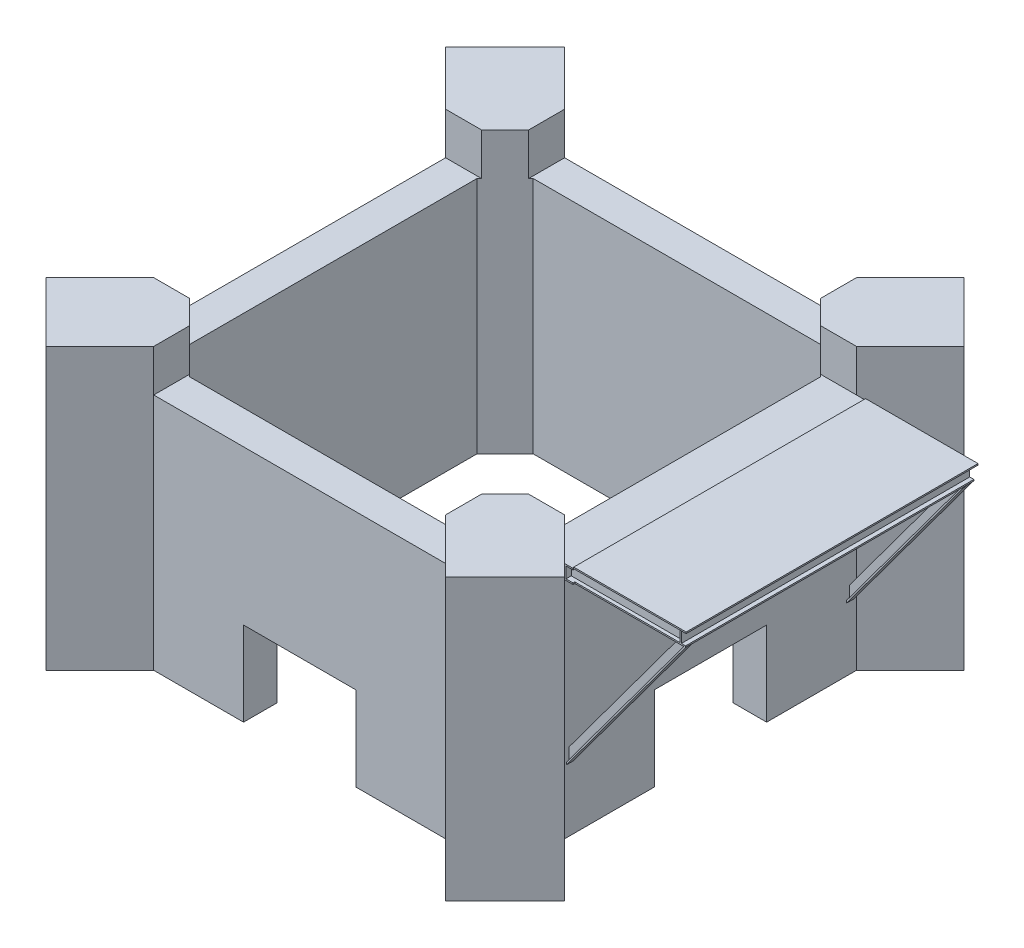
from build123d import *

# Parameters (mm, degrees)
BOSS_EXTRUDE1_DEPTH  = 10000
CUT_EXTRUDE3_DEPTH   = 1500
SKETCH5_W            = 4000
SKETCH5_H            = 3000
CUT_EXTRUDE4_DEPTH   = 1353
SKETCH6_W            = 4000
SKETCH6_H            = 3000
CUT_EXTRUDE5_DEPTH   = 1353
SKETCH7_W            = 10402.254821559
SKETCH7_H            = 500
BOSS_EXTRUDE2_DEPTH  = 50
SKETCH8_W            = 10402.254821559
SKETCH8_H            = 50
BOSS_EXTRUDE3_DEPTH  = 250
SKETCH9_W            = 50
SKETCH9_H            = 400
BOSS_EXTRUDE4_DEPTH  = 4000
SKETCH10_W           = 3600
SKETCH10_H           = 300
BOSS_EXTRUDE5_DEPTH  = 50
SKETCH11_W           = 3600
SKETCH11_H           = 300
BOSS_EXTRUDE6_DEPTH  = 50
SKETCH12_W           = 10277.25482156
SKETCH12_H           = 400
BOSS_EXTRUDE7_DEPTH  = 50
SKETCH13_W           = 350
SKETCH13_H           = 10277.254821559
BOSS_EXTRUDE8_DEPTH  = 50
SKETCH15_W           = 4008.15465075
SKETCH15_H           = 10402.254821559
BOSS_EXTRUDE11_DEPTH = 50
SKETCH14_W           = 350
SKETCH14_H           = 10277.25482156
BOSS_EXTRUDE9_DEPTH  = 50
BOSS_EXTRUDE12_DEPTH = 50
SKETCH17_W           = 238.62741078
SKETCH17_H           = 7184.490164885
BOSS_EXTRUDE17_DEPTH = 50
BOSS_EXTRUDE18_DEPTH = 50
SKETCH19_W           = 250
SKETCH19_H           = 7222.055032397
BOSS_EXTRUDE20_DEPTH = 50


with BuildPart() as part:
    # Sketch1 → Boss-Extrude1 (new body)
    with BuildSketch(Plane(origin=(0, 0, 0), x_dir=(1, 0, 0), z_dir=(0, 1, 0))):
        Polygon((-5000, 7121.320343559), (-7121.32034356, 5000), (-7322.447754339, 5201.127410779), (-7322.447754339, -5201.127410779), (-7121.32034356, -5000), (-5000, -7121.320343559), (-5201.12741078, -7322.447754339), (5201.12741078, -7322.447754339), (5000, -7121.320343559), (7121.320343559, -5000), (7322.447754339, -5201.12741078), (7322.447754339, 5201.12741078), (7121.320343559, 5000), (5000, 7121.320343559), (5201.12741078, 7322.447754339), (-5201.12741078, 7322.447754339), align=None)
        Polygon((-5122.447754339, 6122.447754339), (5122.447754339, 6122.447754339), (6122.447754339, 5122.447754339), (6122.447754339, -5122.447754339), (5122.447754339, -6122.447754339), (-5122.447754339, -6122.447754339), (-6122.447754339, -5122.447754339), (-6122.447754339, 5122.447754339), align=None, mode=Mode.SUBTRACT)
        Polygon((7322.447754339, 7322.447754339), (5201.12741078, 7322.447754339), (5000, 7121.320343559), (7121.320343559, 5000), (7322.447754339, 5201.12741078), align=None)
        Polygon((-7322.447754339, 5201.127410779), (-7121.32034356, 5000), (-5000, 7121.320343559), (-5201.12741078, 7322.447754339), (-7322.447754339, 7322.447754339), align=None)
        Polygon((-7121.32034356, -5000), (-7322.447754339, -5201.127410779), (-7322.447754339, -7322.447754339), (-5201.12741078, -7322.447754339), (-5000, -7121.320343559), align=None)
        Polygon((5000, -7121.320343559), (5201.12741078, -7322.447754339), (7322.447754339, -7322.447754339), (7322.447754339, -5201.12741078), (7121.320343559, -5000), align=None)
        Polygon((7322.447754339, -7322.447754339), (5201.12741078, -7322.447754339), (7121.320343559, -9242.640687119), (9242.640687119, -7121.320343559), (7322.447754339, -5201.12741078), align=None)
        Polygon((7121.320343559, 9242.640687119), (5201.12741078, 7322.447754339), (7322.447754339, 7322.447754339), (7322.447754339, 5201.12741078), (9242.640687119, 7121.320343559), align=None)
        Polygon((-9242.64068712, 7121.320343559), (-7322.447754339, 5201.127410779), (-7322.447754339, 7322.447754339), (-5201.12741078, 7322.447754339), (-7121.32034356, 9242.640687119), align=None)
        Polygon((-7322.447754339, -7322.447754339), (-7322.447754339, -5201.127410779), (-9242.64068712, -7121.320343559), (-7121.32034356, -9242.640687119), (-5201.12741078, -7322.447754339), align=None)
    extrude(amount=BOSS_EXTRUDE1_DEPTH)

    # Sketch4 → Cut-Extrude3 (cut)
    with BuildSketch(Plane(origin=(0, 10000, 0), x_dir=(1, 0, 0), z_dir=(0, 1, 0))):
        Polygon((-5201.12741078, -5201.12741078), (-5201.12741078, -7322.447754339), (5201.12741078, -7322.447754339), (5201.12741078, -5201.12741078), (7322.447754339, -5201.12741078), (7322.447754339, 5201.127410779), (5201.12741078, 5201.127410779), (5201.12741078, 7322.447754339), (-5201.12741078, 7322.447754339), (-5201.12741078, 5201.127410779), (-7322.447754339, 5201.127410779), (-7322.447754339, -5201.12741078), align=None)
    extrude(amount=-CUT_EXTRUDE3_DEPTH, mode=Mode.SUBTRACT)

    # Sketch5 → Cut-Extrude4 (cut)
    with BuildSketch(Plane.XY.offset(7322.447754339)):
        with Locations((0, 1500)):
            Rectangle(SKETCH5_W, SKETCH5_H)
    extrude(amount=-CUT_EXTRUDE4_DEPTH, mode=Mode.SUBTRACT)

    # Sketch6 → Cut-Extrude5 (cut)
    with BuildSketch(Plane(origin=(7322.447754339, 0, 0), x_dir=(0, 0, -1), z_dir=(1, 0, 0))):
        with Locations((0, 1500)):
            Rectangle(SKETCH6_W, SKETCH6_H)
    extrude(amount=-CUT_EXTRUDE5_DEPTH, mode=Mode.SUBTRACT)

    # Sketch7 → Boss-Extrude2 (add)
    with BuildSketch(Plane(origin=(7322.447754339, 0, 0), x_dir=(0, 0, -1), z_dir=(1, 0, 0))):
        with Locations((0, 8250)):
            Rectangle(SKETCH7_W, SKETCH7_H)
    extrude(amount=BOSS_EXTRUDE2_DEPTH)

    # Sketch8 → Boss-Extrude3 (add)
    with BuildSketch(Plane(origin=(7372.447754339, 0, 0), x_dir=(0, 0, -1), z_dir=(1, 0, 0))):
        with Locations((0, 8475)):
            Rectangle(SKETCH8_W, SKETCH8_H)
        with Locations((0, 8025)):
            Rectangle(SKETCH8_W, SKETCH8_H)
    extrude(amount=BOSS_EXTRUDE3_DEPTH)

    # Sketch9 → Boss-Extrude4 (add)
    with BuildSketch(Plane(origin=(7372.447754339, 0, 0), x_dir=(0, 0, -1), z_dir=(1, 0, 0))):
        with Locations((-4988.62741078, 8250)):
            Rectangle(SKETCH9_W, SKETCH9_H)
        with Locations((4988.62741078, 8250)):
            Rectangle(SKETCH9_W, SKETCH9_H)
        with Locations((0, 8250)):
            Rectangle(SKETCH9_W, SKETCH9_H)
        with Locations((2504.038593718, 8250)):
            Rectangle(SKETCH9_W, SKETCH9_H)
        with Locations((-2507.41389495, 8250)):
            Rectangle(SKETCH9_W, SKETCH9_H)
    extrude(amount=BOSS_EXTRUDE4_DEPTH)

    # Sketch10 → Boss-Extrude5 (add)
    with BuildSketch(Plane(origin=(0, 8450, 0), x_dir=(1, 0, 0), z_dir=(0, 1, 0))):
        with Locations((9422.447754339, 4988.62741078)):
            Rectangle(SKETCH10_W, SKETCH10_H)
        with Locations((9422.447754339, 2504.038593718)):
            Rectangle(SKETCH10_W, SKETCH10_H)
        with Locations((9422.447754339, 0)):
            Rectangle(SKETCH10_W, SKETCH10_H)
        with Locations((9422.447754339, -2507.41389495)):
            Rectangle(SKETCH10_W, SKETCH10_H)
        with Locations((9422.447754339, -4988.62741078)):
            Rectangle(SKETCH10_W, SKETCH10_H)
    extrude(amount=BOSS_EXTRUDE5_DEPTH)

    # Sketch11 → Boss-Extrude6 (add)
    with BuildSketch(Plane.XZ.offset(-8050)):
        with Locations((9422.447754339, -4988.62741078)):
            Rectangle(SKETCH11_W, SKETCH11_H)
        with Locations((9422.447754339, -2504.038593718)):
            Rectangle(SKETCH11_W, SKETCH11_H)
        with Locations((9422.447754339, 0)):
            Rectangle(SKETCH11_W, SKETCH11_H)
        with Locations((9422.447754339, 2507.41389495)):
            Rectangle(SKETCH11_W, SKETCH11_H)
        with Locations((9422.447754339, 4988.62741078)):
            Rectangle(SKETCH11_W, SKETCH11_H)
    extrude(amount=BOSS_EXTRUDE6_DEPTH)

    # Sketch12 → Boss-Extrude7 (add)
    with BuildSketch(Plane(origin=(11372.447754339, 0, 0), x_dir=(0, 0, -1), z_dir=(1, 0, 0))):
        with Locations((0, 8250)):
            Rectangle(SKETCH12_W, SKETCH12_H)
    extrude(amount=BOSS_EXTRUDE7_DEPTH)

    # Sketch13 → Boss-Extrude8 (add)
    with BuildSketch(Plane(origin=(0, 8450, 0), x_dir=(1, 0, 0), z_dir=(0, 1, 0))):
        with Locations((11397.447754339, 0)):
            Rectangle(SKETCH13_W, SKETCH13_H)
    extrude(amount=BOSS_EXTRUDE8_DEPTH)

    # Sketch15 → Boss-Extrude11 (add)
    with BuildSketch(Plane(origin=(0, 8500, 0), x_dir=(1, 0, 0), z_dir=(0, 1, 0))):
        with Locations((9651.028693309, 0)):
            Rectangle(SKETCH15_W, SKETCH15_H)
    extrude(amount=BOSS_EXTRUDE11_DEPTH)

    # Sketch14 → Boss-Extrude9 (add)
    with BuildSketch(Plane.XZ.offset(-8050)):
        with Locations((11397.447754339, 0)):
            Rectangle(SKETCH14_W, SKETCH14_H)
    extrude(amount=BOSS_EXTRUDE9_DEPTH)

    # Sketch16 → Boss-Extrude12 (add)
    with BuildSketch(Plane.XY.offset(5000)):
        Polygon((11572.447754339, 8000), (7302.600560807, 2224.405870044), (7302.600560807, 2729.053019193), (11199.36644616, 8000), align=None)
    extrude(amount=BOSS_EXTRUDE12_DEPTH)

    # Sketch17 → Boss-Extrude17 (add)
    with BuildSketch(Plane(origin=(3658.536599047, -2704.724722406, 0), x_dir=(0, 0, -1), z_dir=(0.80411426, -0.594474774, 0))):
        with Locations((-5019.31370539, 9722.750587537)):
            Rectangle(SKETCH17_W, SKETCH17_H)
    extrude(amount=-BOSS_EXTRUDE17_DEPTH)

    # Sketch18 → Boss-Extrude18 (add)
    with BuildSketch(Plane.XY.offset(-5000)):
        Polygon((11199.36644616, 8000), (7302.600560807, 2729.053019193), (7302.600560807, 2224.405870044), (11572.447754339, 8000), align=None)
    extrude(amount=BOSS_EXTRUDE18_DEPTH)

    # Sketch19 → Boss-Extrude20 (add)
    with BuildSketch(Plane(origin=(3658.536599047, -2704.724722406, 0), x_dir=(0, 0, -1), z_dir=(0.80411426, -0.594474774, 0))):
        with Locations((4975, 9701.414827578)):
            Rectangle(SKETCH19_W, SKETCH19_H)
    extrude(amount=-BOSS_EXTRUDE20_DEPTH)


solid = part.part
